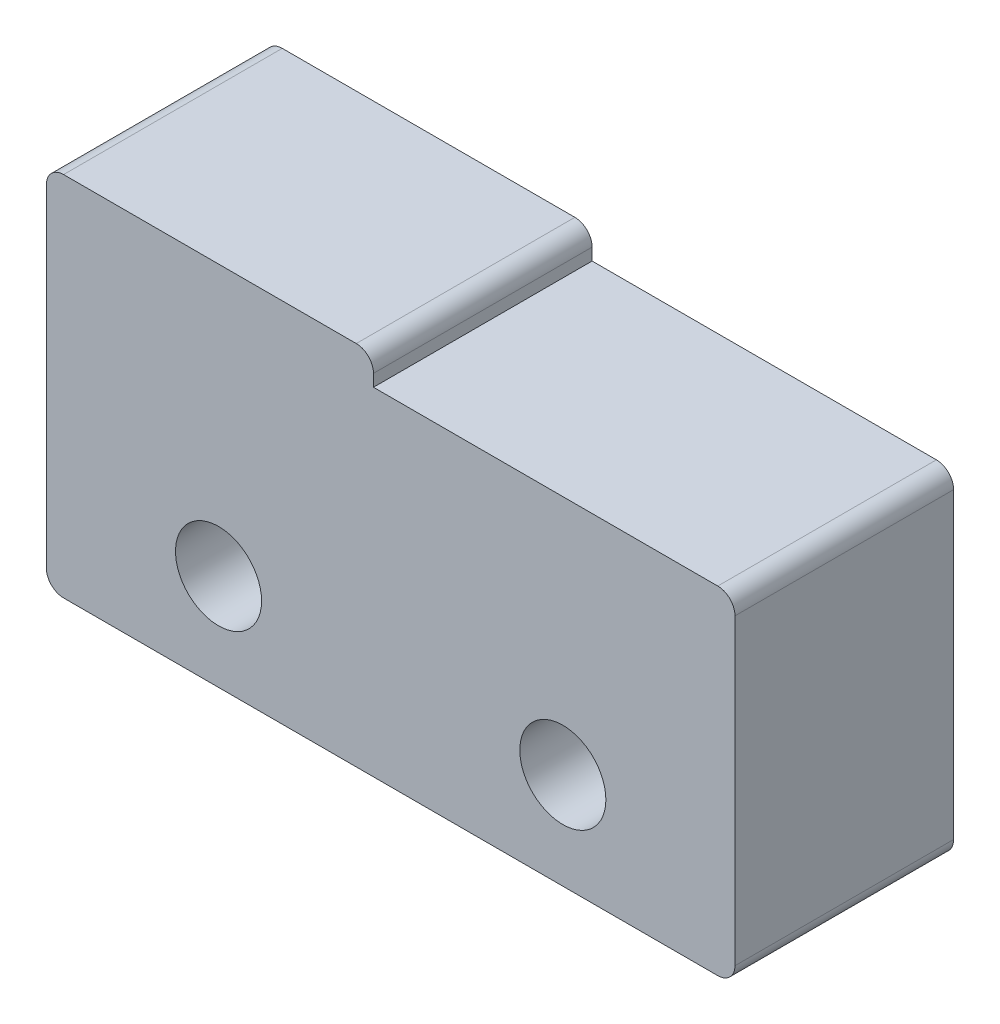
from build123d import *

# Parameters (mm, degrees)
SKETCH1_R           = 1.25
BOSS_EXTRUDE1_DEPTH = 6.35
FILLET1_R           = 0.5


with BuildPart() as part:
    # Sketch1 → Boss-Extrude1 (new body)
    with BuildSketch(Plane.XY):
        Polygon((10, 4.8), (-0.5, 4.8), (-0.5, 5.65), (-10, 5.65), (-10, -5), (10, -5), align=None)
        with Locations((-5, -2.2)):
            Circle(SKETCH1_R, mode=Mode.SUBTRACT)
        with Locations((5, -2.2)):
            Circle(SKETCH1_R, mode=Mode.SUBTRACT)
    extrude(amount=BOSS_EXTRUDE1_DEPTH)

    # Fillet1
    fillet1_edges = [part.edges().sort_by_distance(p)[0] for p in [
        (-10, 5.65, 3.175),
        (-0.5, 5.65, 3.175),
        (10, 4.8, 3.175),
        (10, -5, 3.175),
        (-10, -5, 3.175),
    ]]
    fillet(fillet1_edges, radius=FILLET1_R)


solid = part.part
